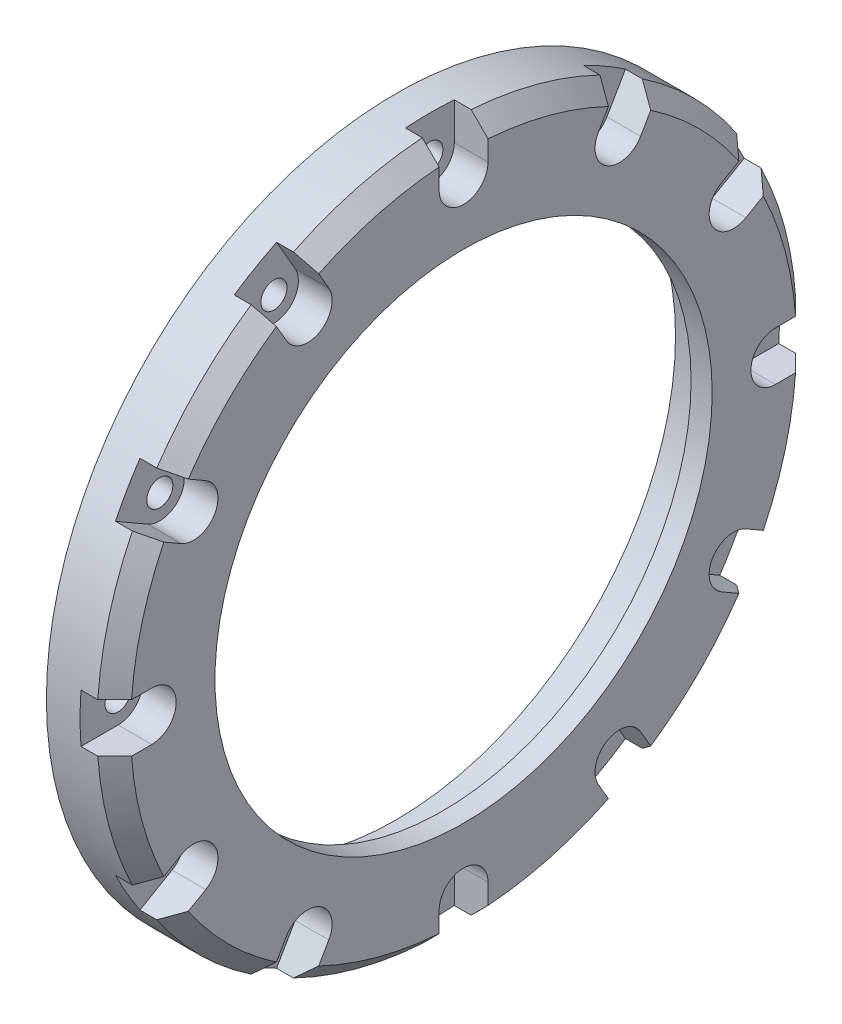
from build123d import *

# Parameters (mm, degrees)
SKETCH_1_R               = 41.5
SKETCH_1_R_2             = 33.15
EXTRUDE_1_DEPTH          = 8
SKETCH_2_R               = 1.55
CUT_EXTRUDE_1_DEPTH      = 8
PATTERN_CIRCULAR_1_COUNT = 12
SKETCH_3_R               = 33.15
SKETCH_3_R_2             = 29.5
EXTRUDE_2_DEPTH          = 2.5
CHAMFER_1_SIZE           = 2
SKETCH_4_R               = 1.55
CUT_EXTRUDE_8_DEPTH      = 4
PATTERN_CIRCULAR_7_COUNT = 12


with BuildPart() as part:
    # 草图1 → 凸台-拉伸1 (new body)
    with BuildSketch(Plane(origin=(0, 0, 0), x_dir=(0, 0, -1), z_dir=(1, 0, 0))):
        Circle(SKETCH_1_R)
        Circle(SKETCH_1_R_2, mode=Mode.SUBTRACT)
    extrude(amount=EXTRUDE_1_DEPTH)

    # 草图2 → 切除-拉伸1 (cut)
    with BuildSketch(Plane.ZY):
        with Locations((0, 37)):
            Circle(SKETCH_2_R)
    cut_extrude_1 = extrude(amount=-CUT_EXTRUDE_1_DEPTH, mode=Mode.SUBTRACT)

    # 阵列(圆周)1: 切除-拉伸1 ×12 about axis
    pattern_circular_1_axis = Axis((0, 0, 0), (1, 0, 0))
    for i in range(1, PATTERN_CIRCULAR_1_COUNT):
        add(cut_extrude_1.rotate(pattern_circular_1_axis, i * 360 / PATTERN_CIRCULAR_1_COUNT), mode=Mode.SUBTRACT)

    # 草图3 → 凸台-拉伸2 (add)
    with BuildSketch(Plane(origin=(8, 0, 0), x_dir=(0, 0, -1), z_dir=(1, 0, 0))):
        Circle(SKETCH_3_R)
        Circle(SKETCH_3_R_2, mode=Mode.SUBTRACT)
    extrude(amount=-EXTRUDE_2_DEPTH)

    # 倒角1
    chamfer_1_edges = [part.edges().sort_by_distance(p)[0] for p in [
        (8, 0, 41.5),
    ]]
    chamfer(chamfer_1_edges, length=CHAMFER_1_SIZE)

    # 草图4 → 切除-拉伸8 (cut)
    with BuildSketch(Plane(origin=(8, 0, 0), x_dir=(0, 0, -1), z_dir=(1, 0, 0))):
        with BuildLine():
            Line((39.393400463, 2.9), (37, 2.9))
            ThreePointArc((37, 2.9), (34.1, 0), (37, -2.9))
            Line((37, -2.9), (39.393400463, -2.9))
            ThreePointArc((39.393400463, -2.9), (39.473341119, -1.450979278), (39.5, 0))
            ThreePointArc((39.5, 0), (39.473341119, 1.450979278), (39.393400463, 2.9))
        make_face()
        with Locations((37, 0)):
            Circle(SKETCH_4_R, mode=Mode.SUBTRACT)
        with BuildLine():
            Line((45, 2.9), (39.393400463, 2.9))
            ThreePointArc((39.393400463, 2.9), (39.473341119, 1.450979278), (39.5, 0))
            ThreePointArc((39.5, 0), (39.473341119, -1.450979278), (39.393400463, -2.9))
            Line((39.393400463, -2.9), (45, -2.9))
            ThreePointArc((45, -2.9), (47.9, 0), (45, 2.9))
        make_face()
    cut_extrude_8 = extrude(amount=-CUT_EXTRUDE_8_DEPTH, mode=Mode.SUBTRACT)

    # 阵列(圆周)7: 切除-拉伸8 ×12 about axis
    pattern_circular_7_axis = Axis((0, 0, 0), (1, 0, 0))
    for i in range(1, PATTERN_CIRCULAR_7_COUNT):
        add(cut_extrude_8.rotate(pattern_circular_7_axis, i * 360 / PATTERN_CIRCULAR_7_COUNT), mode=Mode.SUBTRACT)


solid = part.part
